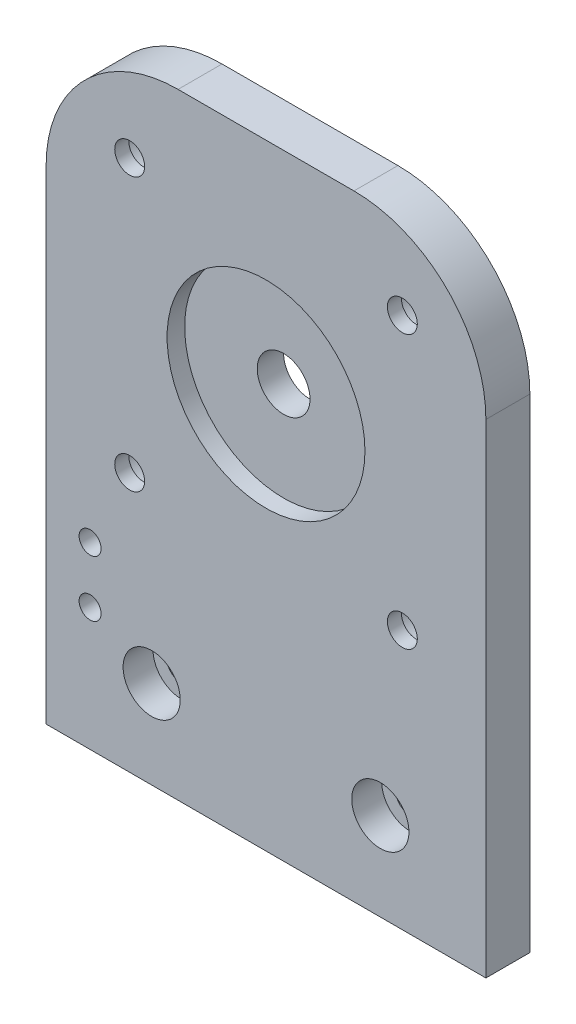
from build123d import *

# Parameters (mm, degrees)
SKIZZE1_R                                            = 3
AUFSATZ_LINEAR_AUSTRAGEN1_DEPTH                      = 5
SKIZZE3_R                                            = 11.25
SCHNITT_LINEAR_AUSTRAGEN1_DEPTH                      = 2
STIRNSENKUNG_F_R_M3_ZYLINDERSCHRAUBE_MIT_D           = 3.4
STIRNSENKUNG_F_R_M3_ZYLINDERSCHRAUBE_MIT_CBORE_D     = 6.5
STIRNSENKUNG_F_R_M3_ZYLINDERSCHRAUBE_MIT_CBORE_DEPTH = 3.4
STIRNSENKUNG_F_R_M3_ZYLINDERSCHRAUBE_2_D             = 3.4
STIRNSENKUNG_F_R_M3_ZYLINDERSCHRAUBE_2_CBORE_D       = 6.5
STIRNSENKUNG_F_R_M3_ZYLINDERSCHRAUBE_2_CBORE_DEPTH   = 3.4
F_2_5_2_5_DURCHMESSER_BOHRUNG1_D                     = 2.5
F_2_5_2_5_DURCHMESSER_BOHRUNG1_DEPTH                 = 5


with BuildPart() as part:
    # Skizze1 → Aufsatz-Linear austragen1 (new body)
    with BuildSketch(Plane.XY):
        with BuildLine():
            Line((0, 0), (50, 0))
            Line((50, 0), (50, 55))
            ThreePointArc((50, 55), (45.606601718, 65.606601718), (35, 70))
            Line((35, 70), (15, 70))
            ThreePointArc((15, 70), (4.393398282, 65.606601718), (0, 55))
            Line((0, 55), (0, 0))
        make_face()
        with Locations((25, 45)):
            Circle(SKIZZE1_R, mode=Mode.SUBTRACT)
    extrude(amount=AUFSATZ_LINEAR_AUSTRAGEN1_DEPTH)

    # Skizze3 → Schnitt-Linear austragen1 (cut)
    with BuildSketch(Plane.XY.offset(5)):
        with Locations((25, 45)):
            Circle(SKIZZE3_R)
    extrude(amount=-SCHNITT_LINEAR_AUSTRAGEN1_DEPTH, mode=Mode.SUBTRACT)

    # Stirnsenkung f_r M3 Zylinderschraube mit (through all)
    with Locations(Plane(origin=(0, 0, 0), x_dir=(-1, 0, 0), z_dir=(0, 0, -1))):
        with Locations((-9.5, 29.5), (-9.5, 60.5), (-40.5, 60.5), (-40.5, 29.5)):
            CounterBoreHole(STIRNSENKUNG_F_R_M3_ZYLINDERSCHRAUBE_MIT_D / 2, STIRNSENKUNG_F_R_M3_ZYLINDERSCHRAUBE_MIT_CBORE_D / 2, STIRNSENKUNG_F_R_M3_ZYLINDERSCHRAUBE_MIT_CBORE_DEPTH)

    # Stirnsenkung f_r M3 Zylinderschraube 2 (through all)
    with Locations(Plane.XY.offset(5)):
        with Locations((38, 10), (12, 10)):
            CounterBoreHole(STIRNSENKUNG_F_R_M3_ZYLINDERSCHRAUBE_2_D / 2, STIRNSENKUNG_F_R_M3_ZYLINDERSCHRAUBE_2_CBORE_D / 2, STIRNSENKUNG_F_R_M3_ZYLINDERSCHRAUBE_2_CBORE_DEPTH)

    # Ø2.5 (2.5) Durchmesser Bohrung1
    with Locations(Plane(origin=(0, 0, 0), x_dir=(-1, 0, 0), z_dir=(0, 0, -1))):
        with Locations((-5, 20.4), (-5, 14)):
            Hole(F_2_5_2_5_DURCHMESSER_BOHRUNG1_D / 2, depth=F_2_5_2_5_DURCHMESSER_BOHRUNG1_DEPTH)


solid = part.part
